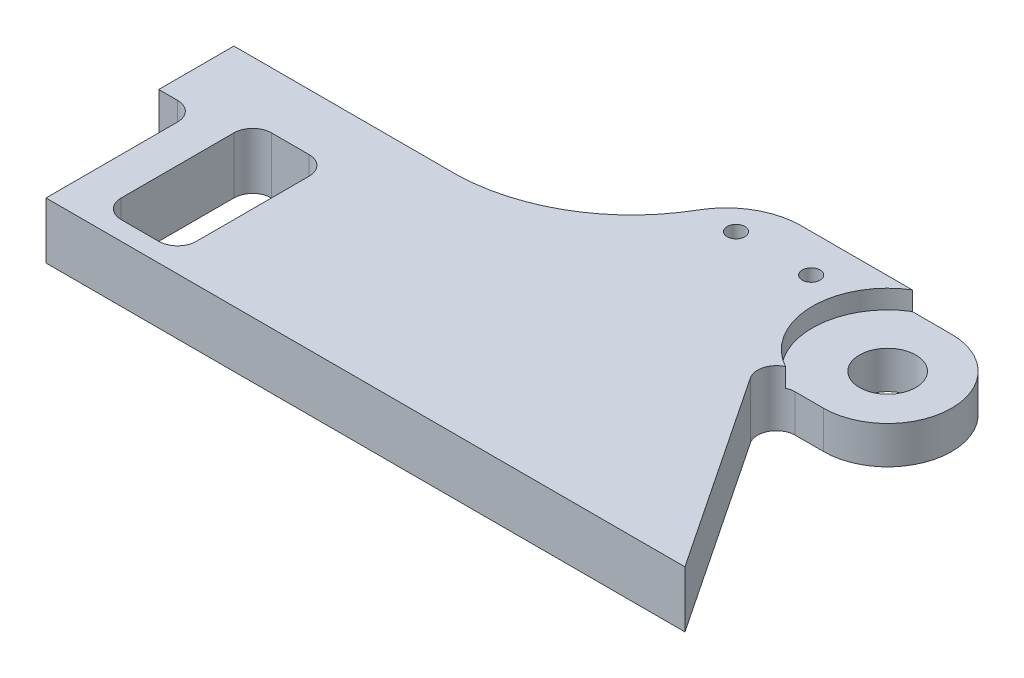
from build123d import *

# Parameters (mm, degrees)
SKETCH1_R           = 4.7625
SKETCH1_R_2         = 1.5
BOSS_EXTRUDE1_DEPTH = 9.525
FILLET1_R           = 3.175
FILLET2_R           = 3.175
SKETCH3_R           = 12.7
CUT_EXTRUDE2_DEPTH  = 3.175
SKETCH4_W           = 12.7
SKETCH4_H           = 25.4
CUT_EXTRUDE3_DEPTH  = 10.525
FILLET3_R           = 3.175


with BuildPart() as part:
    # Sketch1 → Boss-Extrude1 (new body)
    with BuildSketch(Plane(origin=(0, 0, 0), x_dir=(1, 0, 0), z_dir=(0, 1, 0))):
        with BuildLine():
            Line((0, 0), (38.1, 0))
            ThreePointArc((38.1, 0), (52.620300687, 4.403064286), (63.218539249, 15.261399634))
            ThreePointArc((63.218539249, 15.261399634), (67.86863694, 19.924564568), (74.228922018, 21.631986448))
            Line((74.228922018, 21.631986448), (99.628922018, 21.631986448))
            ThreePointArc((99.628922018, 21.631986448), (110.444915242, 10.815993224), (99.628922018, 0))
            Line((99.628922018, 0), (88.9, 0))
            Line((88.9, 0), (114.3, -38.1))
            Line((114.3, -38.1), (6.35, -38.1))
            Line((6.35, -38.1), (6.35, -12.7))
            Line((6.35, -12.7), (0, -12.7))
            Line((0, -12.7), (0, 0))
        make_face()
        with Locations((99.628922018, 10.815993224)):
            Circle(SKETCH1_R, mode=Mode.SUBTRACT)
        with Locations((69.568539249, 15.261399634)):
            Circle(SKETCH1_R_2, mode=Mode.SUBTRACT)
        with Locations((82.268539249, 15.261399634)):
            Circle(SKETCH1_R_2, mode=Mode.SUBTRACT)
    extrude(amount=BOSS_EXTRUDE1_DEPTH)

    # Fillet1
    fillet1_edges = [part.edges().sort_by_distance(p)[0] for p in [
        (88.9, 4.7625, 0),
    ]]
    fillet(fillet1_edges, radius=FILLET1_R)

    # Fillet2
    fillet2_edges = [part.edges().sort_by_distance(p)[0] for p in [
        (6.35, 4.7625, 12.7),
    ]]
    fillet(fillet2_edges, radius=FILLET2_R)

    # Sketch3 → Cut-Extrude2 (cut)
    with BuildSketch(Plane(origin=(0, 9.525, 0), x_dir=(1, 0, 0), z_dir=(0, 1, 0))):
        with Locations((99.628922018, 10.815993224)):
            Circle(SKETCH3_R)
    extrude(amount=-CUT_EXTRUDE2_DEPTH, mode=Mode.SUBTRACT)

    # Sketch4 → Cut-Extrude3 (cut, through all)
    with BuildSketch(Plane(origin=(0, 9.525, 0), x_dir=(1, 0, 0), z_dir=(0, 1, 0))):
        with Locations((19.05, -22.225)):
            Rectangle(SKETCH4_W, SKETCH4_H)
    extrude(amount=-CUT_EXTRUDE3_DEPTH, mode=Mode.SUBTRACT)

    # Fillet3
    fillet3_edges = [part.edges().sort_by_distance(p)[0] for p in [
        (12.7, 4.7625, 9.525),
        (25.4, 4.7625, 9.525),
        (25.4, 4.7625, 34.925),
        (12.7, 4.7625, 34.925),
    ]]
    fillet(fillet3_edges, radius=FILLET3_R)


solid = part.part
